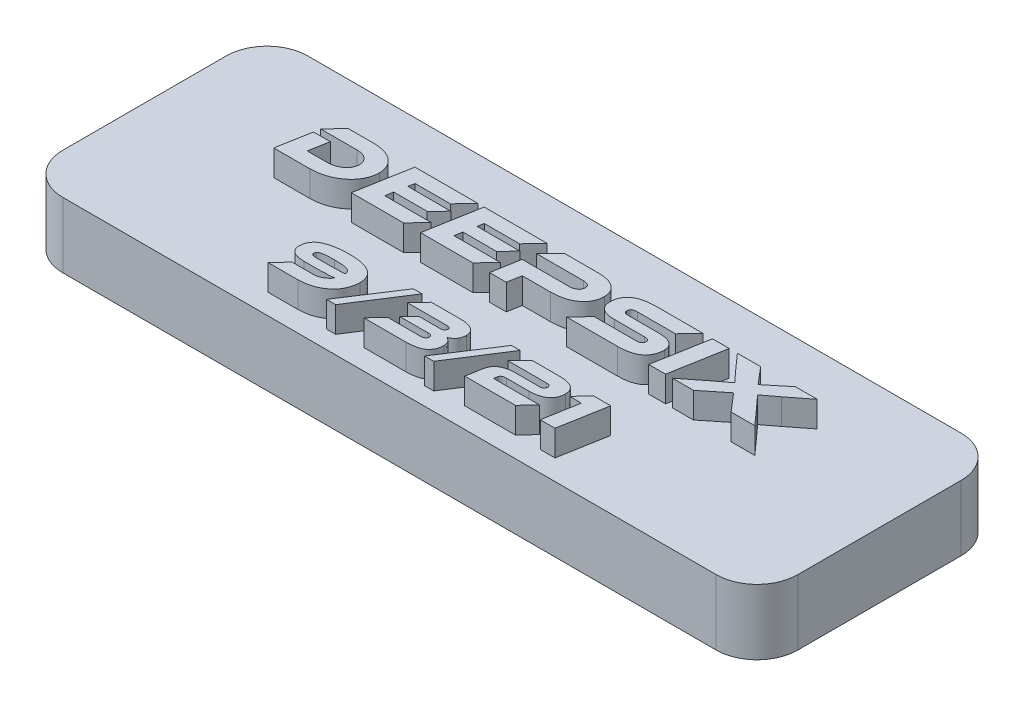
from build123d import *

# Parameters (mm, degrees)
SKETCH1_W           = 57.15
SKETCH1_H           = 19.05
BOSS_EXTRUDE1_DEPTH = 5.08
FILLET1_R           = 3.175
BOSS_EXTRUDE2_DEPTH = 2
SKETCH4_R           = 0.9
CUT_EXTRUDE1_DEPTH  = 4


with BuildPart() as part:
    # Sketch1 → Boss-Extrude1 (new body)
    with BuildSketch(Plane(origin=(0, 0, 0), x_dir=(1, 0, 0), z_dir=(0, 1, 0))):
        Rectangle(SKETCH1_W, SKETCH1_H)
    extrude(amount=BOSS_EXTRUDE1_DEPTH)

    # Fillet1
    fillet1_edges = [part.edges().sort_by_distance(p)[0] for p in [
        (-28.575, 2.54, -9.525),
        (-28.575, 2.54, 9.525),
        (28.575, 2.54, 9.525),
        (28.575, 2.54, -9.525),
    ]]
    fillet(fillet1_edges, radius=FILLET1_R)

    # Sketch3 → Boss-Extrude2 (add)
    with BuildSketch(Plane(origin=(0, 5.08, 0), x_dir=(1, 0, 0), z_dir=(0, 1, 0))):
        with BuildLine():
            Line((17.827066128, 4.208766837), (16.234744528, 2.901365975))
            Line((16.234744528, 2.901365975), (15.122646902, 4.208766837))
            Line((15.122646902, 4.208766837), (13.315488261, 4.208766837))
            Line((13.315488261, 4.208766837), (14.389673468, 3.001937264))
            add(Edge.make_bspline(
                [(14.389673468, 3.001937264), (14.421905514, 2.96565322), (14.483650914, 2.896145602), (14.574020121, 2.796969781), (14.656654904, 2.706215813), (14.731853226, 2.623295629), (14.800064219, 2.549789979), (14.861051093, 2.484598936), (14.913406566, 2.426996634), (14.972853904, 2.36453497), (15.036273052, 2.296940303), (15.105742475, 2.228942305), (15.164154185, 2.173290536), (15.200752002, 2.142040461), (15.217017295, 2.128151884)],
                knots=[0, 0, 0, 0, 0.000145597, 0.000278913, 0.000402513, 0.000513815, 0.000614729, 0.000703345, 0.000781627, 0.000848235, 0.000962032, 0.001059641, 0.001139837, 0.001203991, 0.001203991, 0.001203991, 0.001203991], degree=3))
            add(Edge.make_bspline(
                [(15.217017295, 2.128151884), (15.195035181, 2.113282778), (15.145882675, 2.08003512), (15.064926912, 2.02300337), (14.969735656, 1.952538971), (14.879324565, 1.885783864), (14.796949759, 1.822945094), (14.722685165, 1.767565893), (14.639482632, 1.703189998), (14.546501897, 1.630937748), (14.442983579, 1.551777369), (14.330544192, 1.463622082), (14.208356535, 1.36793568), (14.123681262, 1.30146059), (14.079808986, 1.267018261)],
                knots=[0, 0, 0, 0, 7.9615e-05, 0.000178022, 0.000297052, 0.000434907, 0.000515171, 0.000607866, 0.000712819, 0.000830759, 0.000961128, 0.001103763, 0.001259387, 0.001426717, 0.001426717, 0.001426717, 0.001426717], degree=3))
            Line((14.079808986, 1.267018261), (12.481415042, 0.003655726))
            Line((12.481415042, 0.003655726), (14.105330325, 0.003655726))
            Line((14.105330325, 0.003655726), (15.836664128, 1.392796648))
            Line((15.836664128, 1.392796648), (17.030905328, 0.003655726))
            Line((17.030905328, 0.003655726), (18.875976388, 0.003655726))
            Line((18.875976388, 0.003655726), (17.744922553, 1.267082537))
            add(Edge.make_bspline(
                [(17.744922553, 1.267082537), (17.696325554, 1.320639375), (17.602494366, 1.424047029), (17.467132294, 1.575101317), (17.338987839, 1.71398902), (17.222718612, 1.842642286), (17.119310283, 1.955855654), (17.029791837, 2.049203927), (16.956440111, 2.12197018), (16.911103789, 2.16153788), (16.891748502, 2.178430386)],
                knots=[0, 0, 0, 0, 0.000216956, 0.0004189, 0.000608483, 0.00078386, 0.000939132, 0.001068438, 0.001171871, 0.001248926, 0.001248926, 0.001248926, 0.001248926], degree=3))
            add(Edge.make_bspline(
                [(16.891748502, 2.178430386), (16.913422587, 2.193611207), (16.961906348, 2.227569887), (17.041709822, 2.285528044), (17.13592292, 2.355646824), (17.224966393, 2.421589531), (17.304693112, 2.483177947), (17.375746258, 2.536333869), (17.455085768, 2.596129235), (17.541485147, 2.664537016), (17.637795313, 2.737157725), (17.742177264, 2.816774485), (17.854334354, 2.903684473), (17.932047682, 2.96370059), (17.972279227, 2.994770435)],
                knots=[0, 0, 0, 0, 7.9384e-05, 0.000177578, 0.000295872, 0.000431716, 0.000509971, 0.000598095, 0.000697922, 0.000808005, 0.000928677, 0.001059771, 0.001201845, 0.001354342, 0.001354342, 0.001354342, 0.001354342], degree=3))
            Line((17.972279227, 2.994770435), (19.520487512, 4.208766837))
            Line((19.520487512, 4.208766837), (17.827066128, 4.208766837))
        make_face()
        Polygon((12.679904428, 4.208766837), (11.378244708, 4.208766837), (10.626315064, 0.003655726), (11.934293521, 0.003655726), align=None)
        with BuildLine():
            add(Edge.make_bspline(
                [(6.567629378, 2.512095919), (6.535775236, 2.511504671), (6.476212249, 2.510399118), (6.393389852, 2.522034835), (6.322632194, 2.539116782), (6.264835978, 2.566090201), (6.217459149, 2.599627964), (6.185992235, 2.644809044), (6.165140058, 2.696844794), (6.163885215, 2.734627087), (6.163230242, 2.754347778)],
                knots=[0, 0, 0, 0, 9.5419e-05, 0.000178421, 0.000250262, 0.000312834, 0.000368963, 0.000421992, 0.000475811, 0.000534573, 0.000534573, 0.000534573, 0.000534573], degree=3))
            add(Edge.make_bspline(
                [(6.163230242, 2.754347778), (6.16393416, 2.784095735), (6.165258572, 2.840066044), (6.188843823, 2.91717495), (6.226881216, 2.981488099), (6.283146184, 3.030808944), (6.35558579, 3.066687209), (6.4447633, 3.090054592), (6.550668454, 3.104410249), (6.626957211, 3.105638841), (6.667843575, 3.106297295)],
                knots=[0, 0, 0, 0, 8.8904e-05, 0.000167271, 0.000239077, 0.000310287, 0.000388377, 0.00047954, 0.000585681, 0.000708263, 0.000708263, 0.000708263, 0.000708263], degree=3))
            Line((6.667843575, 3.106297295), (9.600622902, 3.106887389))
            Line((9.600622902, 3.106887389), (10.636895689, 4.206347541))
            Line((10.636895689, 4.206347541), (6.965709778, 4.206347541))
            add(Edge.make_bspline(
                [(6.965709778, 4.206347541), (6.876741316, 4.203761609), (6.705199711, 4.19877563), (6.457529784, 4.177457512), (6.229750002, 4.141917495), (6.020578158, 4.09469606), (5.830218415, 4.035202214), (5.658791063, 3.962028529), (5.506468698, 3.876200662), (5.373887899, 3.776648192), (5.259482496, 3.666680115), (5.158520174, 3.550726447), (5.075014976, 3.425381253), (5.007102523, 3.292730634), (4.953286084, 3.153218365), (4.917105846, 3.005467482), (4.895463072, 2.850382913), (4.894142322, 2.744364115), (4.893469517, 2.690356957)],
                knots=[0, 0, 0, 0, 0.000266987, 0.000514782, 0.000745181, 0.000958069, 0.001157556, 0.001342649, 0.001516245, 0.001680793, 0.001838563, 0.001991558, 0.002141147, 0.00228915, 0.002437874, 0.00258864, 0.002744556, 0.002906454, 0.002906454, 0.002906454, 0.002906454], degree=3))
            add(Edge.make_bspline(
                [(4.893469517, 2.690356957), (4.894147376, 2.65342143), (4.895475926, 2.581030664), (4.911756384, 2.475706559), (4.936661127, 2.375589904), (4.974981165, 2.282563101), (5.021516713, 2.194076325), (5.08062567, 2.112868507), (5.149954093, 2.037166957), (5.229709741, 1.967522981), (5.321066112, 1.904593689), (5.424893806, 1.851271808), (5.539975017, 1.805334795), (5.667136696, 1.768282015), (5.805812009, 1.738303218), (5.95670207, 1.716643202), (6.119102931, 1.70292758), (6.231458964, 1.700608811), (6.289383575, 1.699413382)],
                knots=[0, 0, 0, 0, 0.000110707, 0.000216977, 0.00031897, 0.000419465, 0.000518033, 0.000618244, 0.00071983, 0.000825434, 0.000935228, 0.00105176, 0.001174832, 0.001306435, 0.001448624, 0.001600142, 0.001763438, 0.001937214, 0.001937214, 0.001937214, 0.001937214], degree=3))
            Line((6.289383575, 1.699413382), (8.595943797, 1.700326644))
            add(Edge.make_bspline(
                [(8.595943797, 1.700326644), (8.627002725, 1.699313028), (8.685116054, 1.697416487), (8.766553972, 1.687207317), (8.835667195, 1.668380389), (8.893309552, 1.642063474), (8.938553635, 1.606942061), (8.971304408, 1.563227804), (8.989955489, 1.510969449), (8.992256461, 1.473764602), (8.99345285, 1.454419952)],
                knots=[0, 0, 0, 0, 9.3208e-05, 0.000174398, 0.000245596, 0.000307341, 0.000363306, 0.000415597, 0.000469096, 0.000527043, 0.000527043, 0.000527043, 0.000527043], degree=3))
            add(Edge.make_bspline(
                [(8.99345285, 1.454419952), (8.992883896, 1.426558059), (8.991807608, 1.373851879), (8.970592701, 1.299313488), (8.930618572, 1.236775206), (8.873457266, 1.18629644), (8.799907561, 1.147494808), (8.709936912, 1.122375599), (8.604262417, 1.106843419), (8.528517367, 1.105781815), (8.487925362, 1.105212899)],
                knots=[0, 0, 0, 0, 8.3369e-05, 0.000157708, 0.000229223, 0.000303015, 0.000383999, 0.00047655, 0.000581916, 0.000703584, 0.000703584, 0.000703584, 0.000703584], degree=3))
            Line((8.487925362, 1.105212899), (5.281404943, 1.105536066))
            Line((5.281404943, 1.105536066), (4.249871655, 0.006075914))
            Line((4.249871655, 0.006075914), (8.19154466, 0.006075914))
            add(Edge.make_bspline(
                [(8.19154466, 0.006075914), (8.281244635, 0.008195652), (8.454473735, 0.012289302), (8.704369319, 0.034973018), (8.934899652, 0.071529273), (9.14625808, 0.119633447), (9.337781918, 0.182966981), (9.509690024, 0.258409984), (9.662591144, 0.347126316), (9.794603754, 0.450678649), (9.910000902, 0.563538193), (10.00775714, 0.686232854), (10.092324943, 0.815323858), (10.158838841, 0.953986469), (10.211730673, 1.099572383), (10.246666736, 1.254064377), (10.268813824, 1.415977891), (10.269343186, 1.52686752), (10.269612657, 1.583315749)],
                knots=[0, 0, 0, 0, 0.000269123, 0.000519731, 0.000752079, 0.000968942, 0.001169275, 0.001356304, 0.001531274, 0.001698041, 0.001858355, 0.0020144, 0.002167809, 0.002320308, 0.002474717, 0.002631488, 0.002794654, 0.002963834, 0.002963834, 0.002963834, 0.002963834], degree=3))
            add(Edge.make_bspline(
                [(10.269612657, 1.583315749), (10.267911832, 1.620553939), (10.264589517, 1.693293312), (10.24739464, 1.798622733), (10.218801084, 1.896846315), (10.179479639, 1.987941703), (10.128797123, 2.071957931), (10.066901021, 2.148122699), (9.994968474, 2.217510935), (9.911577648, 2.278743157), (9.818394786, 2.333809533), (9.713761444, 2.380099861), (9.599225452, 2.420439988), (9.473502129, 2.453105293), (9.336863127, 2.478118666), (9.18985923, 2.497622997), (9.031994275, 2.508032791), (8.923380917, 2.510110073), (8.867299517, 2.511182657)],
                knots=[0, 0, 0, 0, 0.000111766, 0.000218319, 0.000319279, 0.000417948, 0.00051515, 0.000612661, 0.00071158, 0.000814148, 0.000922328, 0.001035661, 0.001156803, 0.001286294, 0.001424887, 0.001573313, 0.001730929, 0.001899196, 0.001899196, 0.001899196, 0.001899196], degree=3))
            Line((8.867299517, 2.511182657), (6.567629378, 2.512095919))
        make_face()
        with BuildLine():
            add(Edge.make_bspline(
                [(4.334921063, 2.8527417), (4.333289643, 2.90231375), (4.330083108, 2.999746992), (4.306334363, 3.14197663), (4.270275615, 3.277108946), (4.218959506, 3.404564931), (4.151208352, 3.52306029), (4.07019455, 3.634253816), (3.975544816, 3.738655138), (3.865265959, 3.833025271), (3.742473371, 3.919798167), (3.605379714, 3.99434896), (3.455616067, 4.058920389), (3.292017684, 4.110009865), (3.116249204, 4.152486481), (2.927321206, 4.182135489), (2.725432173, 4.200187529), (2.586485545, 4.204039197), (2.514839275, 4.206025266)],
                knots=[0, 0, 0, 0, 0.000148656, 0.000292181, 0.000431448, 0.000567592, 0.000703091, 0.000839863, 0.000979636, 0.0011248, 0.001274431, 0.001429905, 0.001592071, 0.00176293, 0.001943415, 0.002134132, 0.002336075, 0.002551059, 0.002551059, 0.002551059, 0.002551059], degree=3))
            Line((2.514839275, 4.206025266), (-0.138744384, 4.206347541))
            Line((-0.138744384, 4.206347541), (-1.200292118, 3.106887389))
            Line((-1.200292118, 3.106887389), (2.439300111, 3.106887389))
            add(Edge.make_bspline(
                [(2.439300111, 3.106887389), (2.482542214, 3.105271439), (2.563862702, 3.102232508), (2.678131098, 3.082562512), (2.776238637, 3.049448147), (2.857548231, 3.002533217), (2.921309469, 2.944054673), (2.967950045, 2.875128596), (2.996394846, 2.795454755), (2.999547474, 2.738736187), (3.001169517, 2.709554203)],
                knots=[0, 0, 0, 0, 0.000129715, 0.000243941, 0.000346575, 0.000438764, 0.000523505, 0.000603877, 0.000686278, 0.000773603, 0.000773603, 0.000773603, 0.000773603], degree=3))
            add(Edge.make_bspline(
                [(3.001169517, 2.709554203), (3.0003594, 2.68940885), (2.99877984, 2.650129607), (2.98956586, 2.592714955), (2.97403491, 2.538325425), (2.951740618, 2.486997986), (2.924444503, 2.438376615), (2.891005306, 2.39293274), (2.85131362, 2.350727054), (2.78983583, 2.297975724), (2.698810384, 2.241909704), (2.571510264, 2.194774305), (2.426050313, 2.164290223), (2.322422657, 2.160374672), (2.268017536, 2.158318986)],
                knots=[0, 0, 0, 0, 6.0445e-05, 0.000117855, 0.000173984, 0.00022968, 0.000285354, 0.000340937, 0.0003985, 0.000458785, 0.000583594, 0.000716696, 0.00086425, 0.001027338, 0.001027338, 0.001027338, 0.001027338], degree=3))
            Line((2.268017536, 2.158318986), (-1.370898003, 2.158641261))
            Line((-1.370898003, 2.158641261), (-1.750022194, 0.003655726))
            Line((-1.750022194, 0.003655726), (-0.448362473, 0.003655726))
            Line((-0.448362473, 0.003655726), (-0.258800378, 1.059182001))
            Line((-0.258800378, 1.059182001), (1.9527574, 1.059182001))
            add(Edge.make_bspline(
                [(1.9527574, 1.059182001), (2.042992396, 1.061335988), (2.218714228, 1.065530619), (2.474081198, 1.093356204), (2.715190122, 1.132182566), (2.940529028, 1.189220643), (3.151872042, 1.259358952), (3.347791102, 1.345243266), (3.528983327, 1.445895761), (3.693839827, 1.561391424), (3.841774325, 1.688577723), (3.970621648, 1.826902301), (4.081780069, 1.973467635), (4.171571363, 2.131094192), (4.242786728, 2.29789434), (4.293631121, 2.47443279), (4.326549341, 2.660218917), (4.332097477, 2.787424299), (4.334921063, 2.8527417)],
                knots=[0, 0, 0, 0, 0.000270666, 0.000527089, 0.000769951, 0.001002752, 0.001223611, 0.001437281, 0.001643542, 0.001844398, 0.002040129, 0.002227698, 0.002410529, 0.002590701, 0.002770513, 0.002953344, 0.003140755, 0.003334978, 0.003334978, 0.003334978, 0.003334978], degree=3))
        make_face()
        Polygon((-5.616067654, 1.105536066), (-5.51496787, 1.700326644), (-2.911648429, 1.700326644), (-2.001750372, 2.629107706), (-5.344361984, 2.629107706), (-5.255899673, 3.106887389), (-2.519886766, 3.106887389), (-1.477295242, 4.206347541), (-6.367997299, 4.206347541), (-7.119926943, 0.006075914), (-3.050660632, 0.006075914), (-2.014387845, 1.105536066), align=None)
        Polygon((-10.998609876, 1.105536066), (-10.897510092, 1.700326644), (-8.294190651, 1.700326644), (-7.384292594, 2.629107706), (-10.726904207, 2.629107706), (-10.638441896, 3.106887389), (-7.902428988, 3.106887389), (-6.859837464, 4.206347541), (-11.750539521, 4.206347541), (-12.502469165, 0.006075914), (-8.433202854, 0.006075914), (-7.396930067, 1.105536066), align=None)
        with BuildLine():
            add(Edge.make_bspline(
                [(-12.740613578, 2.425376215), (-12.743489292, 2.490366785), (-12.749139702, 2.618064917), (-12.780947082, 2.803986167), (-12.82957769, 2.980115123), (-12.895111257, 3.146960648), (-12.981308413, 3.303299496), (-13.084740044, 3.450058323), (-13.206982425, 3.586303096), (-13.345541518, 3.712179584), (-13.500548921, 3.825344313), (-13.668963286, 3.925395962), (-13.851178821, 4.009390478), (-14.046042357, 4.079106767), (-14.2541122, 4.133528035), (-14.475311252, 4.173811565), (-14.709750897, 4.198189582), (-14.870496912, 4.203371321), (-14.952826618, 4.206025266)],
                knots=[0, 0, 0, 0, 0.000195009, 0.000383167, 0.000564368, 0.00074244, 0.000919581, 0.001098646, 0.001279935, 0.00146761, 0.001659228, 0.001854731, 0.002054318, 0.002260196, 0.002474835, 0.002698788, 0.00293411, 0.003181175, 0.003181175, 0.003181175, 0.003181175], degree=3))
            Line((-14.952826618, 4.206025266), (-16.948892092, 4.206347541))
            Line((-16.948892092, 4.206347541), (-17.978846142, 3.106887389))
            Line((-17.978846142, 3.106887389), (-15.148052187, 3.106887389))
            add(Edge.make_bspline(
                [(-15.148052187, 3.106887389), (-15.108540287, 3.105364711), (-15.031324045, 3.102389015), (-14.918702398, 3.089591847), (-14.812009382, 3.069582481), (-14.711161026, 3.04202105), (-14.615798939, 3.008030543), (-14.527668541, 2.964107485), (-14.444805262, 2.914773344), (-14.368041927, 2.858665576), (-14.300127246, 2.795181395), (-14.238448718, 2.72884043), (-14.188618491, 2.655711823), (-14.145804657, 2.579167986), (-14.111573945, 2.49778013), (-14.088578205, 2.411231968), (-14.07204699, 2.320728819), (-14.069320272, 2.258648084), (-14.067924976, 2.22688058)],
                knots=[0, 0, 0, 0, 0.000118592, 0.000231759, 0.000339692, 0.000443921, 0.000545141, 0.000642853, 0.0007388, 0.00083424, 0.000927403, 0.001017368, 0.001105364, 0.001192113, 0.001280223, 0.00136938, 0.001460305, 0.001555592, 0.001555592, 0.001555592, 0.001555592], degree=3))
            add(Edge.make_bspline(
                [(-14.067924976, 2.22688058), (-14.07036942, 2.185642711), (-14.075164159, 2.104755276), (-14.09770486, 1.98706422), (-14.131211115, 1.87545354), (-14.178338585, 1.770616802), (-14.237584214, 1.672112744), (-14.307872606, 1.579018173), (-14.392451795, 1.493971369), (-14.486889881, 1.414841832), (-14.591107162, 1.343689091), (-14.70276201, 1.281927096), (-14.820395465, 1.227960987), (-14.94566522, 1.185692043), (-15.076826559, 1.150471437), (-15.215174653, 1.126576329), (-15.359501459, 1.109169924), (-15.458299838, 1.106548421), (-15.508632609, 1.105212899)],
                knots=[0, 0, 0, 0, 0.00012382, 0.000242871, 0.000358539, 0.000472706, 0.000586683, 0.000702784, 0.000821729, 0.000945681, 0.001071953, 0.001199634, 0.001328098, 0.001459638, 0.001595783, 0.001735109, 0.00188048, 0.002031451, 0.002031451, 0.002031451, 0.002031451], degree=3))
            Line((-15.508632609, 1.105212899), (-17.02471693, 1.105536066))
            Line((-17.02471693, 1.105536066), (-16.75301126, 2.623662059))
            Line((-16.75301126, 2.623662059), (-18.060989717, 2.623662059))
            Line((-18.060989717, 2.623662059), (-18.528576218, 0.006075914))
            Line((-18.528576218, 0.006075914), (-15.697782263, 0.006075914))
            add(Edge.make_bspline(
                [(-15.697782263, 0.006075914), (-15.595914887, 0.00973645), (-15.39575895, 0.016928919), (-15.10238127, 0.055361686), (-14.821787737, 0.113609118), (-14.553911214, 0.192345638), (-14.298469148, 0.290947451), (-14.056292615, 0.411678855), (-13.825841974, 0.551302588), (-13.646467493, 0.685730436), (-13.511181152, 0.801137626), (-13.415990539, 0.891127884), (-13.32649999, 0.98286194), (-13.243606673, 1.077854124), (-13.166845226, 1.175378809), (-13.096669559, 1.275986307), (-13.031941618, 1.378755373), (-12.974811286, 1.484675691), (-12.923236233, 1.592866707), (-12.878347962, 1.703675086), (-12.840141023, 1.817381495), (-12.807043609, 1.933500983), (-12.78018743, 2.052449268), (-12.761710277, 2.174419147), (-12.747278018, 2.298802205), (-12.743428298, 2.38285802), (-12.740613578, 2.425376215)],
                knots=[0, 0, 0, 0, 0.000305659, 0.00060058, 0.000886364, 0.001164634, 0.001437273, 0.001706688, 0.001975409, 0.002244537, 0.002378097, 0.002508729, 0.002637378, 0.002762417, 0.002886772, 0.003009517, 0.003130255, 0.003250927, 0.003370328, 0.003489667, 0.003609348, 0.003730019, 0.003851781, 0.003974869, 0.004099948, 0.004227226, 0.004227226, 0.004227226, 0.004227226], degree=3))
        make_face()
        Polygon((9.710846154, -5.218973535), (10.612055948, -5.218973535), (10.131042132, -7.93430124), (11.275523281, -7.93430124), (11.93346172, -4.256945902), (10.578882582, -4.256945902), align=None)
        with BuildLine():
            Line((4.894237041, -5.218973535), (7.885368935, -5.218973535))
            add(Edge.make_bspline(
                [(7.885368935, -5.218973535), (7.913069849, -5.218922741), (7.964916224, -5.218827674), (8.037645227, -5.225918073), (8.099169268, -5.242216387), (8.150999805, -5.26353583), (8.191093194, -5.294908436), (8.219407194, -5.334273792), (8.236959171, -5.381008794), (8.238183871, -5.4147712), (8.238818237, -5.432259348)],
                knots=[0, 0, 0, 0, 8.3099e-05, 0.000155531, 0.000218392, 0.000273538, 0.000322508, 0.000368908, 0.000417497, 0.000469711, 0.000469711, 0.000469711, 0.000469711], degree=3))
            add(Edge.make_bspline(
                [(8.238818237, -5.432259348), (8.238178443, -5.458018948), (8.236968839, -5.506720508), (8.216406453, -5.573936821), (8.183120077, -5.630194031), (8.133906454, -5.673414306), (8.070375355, -5.704561408), (7.992641188, -5.726311626), (7.899516029, -5.738498194), (7.832514384, -5.73961472), (7.796481685, -5.740215175)],
                knots=[0, 0, 0, 0, 7.6993e-05, 0.000145564, 0.000208395, 0.000270703, 0.000339032, 0.00041902, 0.000511893, 0.000619952, 0.000619952, 0.000619952, 0.000619952], degree=3))
            Line((7.796481685, -5.740215175), (6.038718191, -5.739416071))
            add(Edge.make_bspline(
                [(6.038718191, -5.739416071), (5.983116035, -5.740560639), (5.874862873, -5.742789025), (5.716867546, -5.753609346), (5.568148187, -5.772857955), (5.428525319, -5.798779792), (5.298262121, -5.833149331), (5.177183268, -5.875619954), (5.064915888, -5.92500466), (4.961714021, -5.98174212), (4.868244824, -6.047028209), (4.783719331, -6.120143527), (4.708318722, -6.201107035), (4.6423177, -6.289606037), (4.585936126, -6.385733808), (4.538840371, -6.489539314), (4.499893008, -6.600822081), (4.482571332, -6.678800473), (4.473758291, -6.718474855)],
                knots=[0, 0, 0, 0, 0.000166829, 0.000324804, 0.000474816, 0.000616477, 0.000750546, 0.000878553, 0.001001026, 0.001118108, 0.001231277, 0.001342418, 0.001452782, 0.001562526, 0.00167296, 0.001786425, 0.001904052, 0.002025887, 0.002025887, 0.002025887, 0.002025887], degree=3))
            Line((4.473758291, -6.718474855), (4.25841418, -7.932183575))
            Line((4.25841418, -7.932183575), (8.194987024, -7.932183575))
            Line((8.194987024, -7.932183575), (9.101725713, -6.970155942))
            Line((9.101725713, -6.970155942), (5.530059902, -6.970155942))
            Line((5.530059902, -6.970155942), (5.579819952, -6.707239748))
            add(Edge.make_bspline(
                [(5.579819952, -6.707239748), (5.583597476, -6.686112106), (5.590920233, -6.645156023), (5.619631586, -6.590591717), (5.657992279, -6.543848716), (5.70933161, -6.508043577), (5.770407077, -6.47963759), (5.842724697, -6.461031101), (5.925788118, -6.450993538), (5.984711628, -6.450679637), (6.015937083, -6.450513291)],
                knots=[0, 0, 0, 0, 6.4036e-05, 0.000124134, 0.000182613, 0.000243892, 0.000310094, 0.000383827, 0.000466868, 0.000560486, 0.000560486, 0.000560486, 0.000560486], degree=3))
            Line((6.015937083, -6.450513291), (7.774791046, -6.449714187))
            add(Edge.make_bspline(
                [(7.774791046, -6.449714187), (7.840472071, -6.448593152), (7.967806512, -6.446419826), (8.151704361, -6.426694059), (8.323120971, -6.400940141), (8.480967857, -6.361961645), (8.626721851, -6.315052912), (8.758063106, -6.255202462), (8.877536221, -6.187512089), (8.982248661, -6.107690588), (9.074831853, -6.020066732), (9.155288214, -5.925525662), (9.223067099, -5.823724541), (9.278819901, -5.715194429), (9.32095587, -5.599220599), (9.351651306, -5.476792913), (9.369306651, -5.347458364), (9.371259605, -5.259004345), (9.372255658, -5.21389067)],
                knots=[0, 0, 0, 0, 0.00019697, 0.000381861, 0.000554393, 0.000716581, 0.000869107, 0.001013024, 0.00114885, 0.001280192, 0.001406932, 0.001530654, 0.001651783, 0.001773055, 0.001895792, 0.002021116, 0.002151095, 0.002286391, 0.002286391, 0.002286391, 0.002286391], degree=3))
            add(Edge.make_bspline(
                [(9.372255658, -5.21389067), (9.371803203, -5.1780961), (9.370917459, -5.108023129), (9.354707611, -5.005989197), (9.330715539, -4.909275966), (9.294180836, -4.818686266), (9.246546483, -4.734234215), (9.188467441, -4.655338408), (9.120099814, -4.582231577), (9.040805374, -4.515185386), (8.949982457, -4.455053695), (8.846403837, -4.402688892), (8.730170716, -4.359688685), (8.601983237, -4.322394884), (8.461180228, -4.294289614), (8.307833182, -4.27367202), (8.141966652, -4.26108405), (8.027137036, -4.258543735), (7.967657132, -4.257227893)],
                knots=[0, 0, 0, 0, 0.000107259, 0.000209975, 0.000309113, 0.00040566, 0.000501999, 0.00059927, 0.000698874, 0.0008016, 0.000910084, 0.001024914, 0.001148961, 0.001281358, 0.001425053, 0.00157924, 0.00174531, 0.001923772, 0.001923772, 0.001923772, 0.001923772], degree=3))
            Line((7.967657132, -4.257227893), (5.80097573, -4.256945902))
            Line((5.80097573, -4.256945902), (4.894237041, -5.218973535))
        make_face()
        Polygon((4.0084266, -4.05005839), (1.343499478, -8.139071868), (2.056726861, -8.139071868), (4.682951722, -4.05005839), align=None)
        with BuildLine():
            Line((-3.584918597, -7.932183575), (-0.32839977, -7.932183575))
            add(Edge.make_bspline(
                [(-0.32839977, -7.932183575), (-0.286383473, -7.93123587), (-0.204058777, -7.929378983), (-0.083062886, -7.923037277), (0.032654988, -7.913254577), (0.143430248, -7.901623973), (0.248731668, -7.886187648), (0.348917171, -7.869042189), (0.44351634, -7.847894486), (0.532746284, -7.825100472), (0.616861791, -7.799290342), (0.695389706, -7.77082736), (0.768980747, -7.739583859), (0.836820825, -7.704897995), (0.900347943, -7.668886302), (0.957258697, -7.627851966), (1.010281081, -7.586408565), (1.071505268, -7.526093275), (1.139716862, -7.447939794), (1.210293914, -7.349103621), (1.270061869, -7.247349748), (1.317566646, -7.141977162), (1.353040099, -7.033365496), (1.376318121, -6.921258258), (1.387751117, -6.805632209), (1.386190462, -6.727558847), (1.38540128, -6.688079215)],
                knots=[0, 0, 0, 0, 0.000126077, 0.000247029, 0.000363409, 0.000474443, 0.000581116, 0.000682639, 0.000779289, 0.000871831, 0.000958868, 0.001043129, 0.001122322, 0.001198517, 0.00127164, 0.001341101, 0.001408809, 0.001473297, 0.001598583, 0.001719557, 0.001837129, 0.001952051, 0.002065626, 0.002179204, 0.002294931, 0.002413314, 0.002413314, 0.002413314, 0.002413314], degree=3))
            add(Edge.make_bspline(
                [(1.38540128, -6.688079215), (1.383378638, -6.645034748), (1.379486094, -6.562196351), (1.354941173, -6.444259027), (1.313727655, -6.339492999), (1.258278681, -6.247902175), (1.189498154, -6.171048672), (1.111679574, -6.10652163), (1.02360285, -6.055707807), (0.958996435, -6.034777591), (0.926267138, -6.024174444)],
                knots=[0, 0, 0, 0, 0.000129139, 0.000248525, 0.000359482, 0.000465388, 0.000567951, 0.000667397, 0.000767703, 0.000870689, 0.000870689, 0.000870689, 0.000870689], degree=3))
            add(Edge.make_bspline(
                [(0.926267138, -6.024174444), (0.967597793, -6.009960653), (1.050881944, -5.981318874), (1.167342108, -5.914739414), (1.277069116, -5.831227741), (1.361893804, -5.748532962), (1.423284875, -5.672798575), (1.46461194, -5.610121102), (1.498699672, -5.541280496), (1.528345607, -5.468161351), (1.551857412, -5.389726388), (1.567910247, -5.306040388), (1.580621101, -5.217443624), (1.583235735, -5.156345524), (1.584572711, -5.125103406)],
                knots=[0, 0, 0, 0, 0.000130881, 0.000263734, 0.000400196, 0.000543864, 0.000617818, 0.000692362, 0.000768557, 0.000847875, 0.000928857, 0.001013724, 0.001103318, 0.001197072, 0.001197072, 0.001197072, 0.001197072], degree=3))
            add(Edge.make_bspline(
                [(1.584572711, -5.125103406), (1.583232965, -5.090373417), (1.580629974, -5.022896543), (1.563583248, -4.924759117), (1.53551598, -4.833556952), (1.497778687, -4.74840209), (1.449247298, -4.670190772), (1.390585569, -4.598383368), (1.320535253, -4.534139714), (1.241382205, -4.475547046), (1.152050841, -4.424861588), (1.054892809, -4.380021469), (0.949596513, -4.341403135), (0.83580636, -4.310565354), (0.713906689, -4.286619559), (0.583737532, -4.270262105), (0.445441228, -4.259706834), (0.350369752, -4.258068877), (0.301556745, -4.257227893)],
                knots=[0, 0, 0, 0, 0.000104182, 0.000202415, 0.000297803, 0.000389821, 0.000481053, 0.000573127, 0.000667078, 0.000765468, 0.000867956, 0.000974605, 0.001086203, 0.001203992, 0.00132792, 0.001458586, 0.001597356, 0.00174379, 0.00174379, 0.00174379, 0.00174379], degree=3))
            Line((0.301556745, -4.257227893), (-2.014712575, -4.256945902))
            Line((-2.014712575, -4.256945902), (-2.921451264, -5.218973535))
            Line((-2.921451264, -5.218973535), (0.174729625, -5.218973535))
            add(Edge.make_bspline(
                [(0.174729625, -5.218973535), (0.192782503, -5.219195663), (0.227868319, -5.219627369), (0.278607316, -5.228283394), (0.326267388, -5.240429742), (0.369072365, -5.259411957), (0.40660968, -5.284007636), (0.434912262, -5.317589756), (0.451051155, -5.359825366), (0.45425199, -5.390000635), (0.455934601, -5.405863134)],
                knots=[0, 0, 0, 0, 5.4079e-05, 0.000105103, 0.000154, 0.000201268, 0.000244977, 0.000287582, 0.000330657, 0.000378396, 0.000378396, 0.000378396, 0.000378396], degree=3))
            add(Edge.make_bspline(
                [(0.455934601, -5.405863134), (0.454096284, -5.430312402), (0.450621522, -5.476526055), (0.428791972, -5.540002066), (0.393505772, -5.592061965), (0.344494627, -5.629761186), (0.288180517, -5.655905201), (0.226965097, -5.675731181), (0.160648348, -5.686777079), (0.114689202, -5.68773353), (0.09118692, -5.688222633)],
                knots=[0, 0, 0, 0, 7.3319e-05, 0.000138587, 0.00019894, 0.000259277, 0.000321525, 0.000384513, 0.000451841, 0.000522304, 0.000522304, 0.000522304, 0.000522304], degree=3))
            Line((0.09118692, -5.688222633), (-1.550285442, -5.688222633))
            Line((-1.550285442, -5.688222633), (-2.285628403, -6.449714187))
            Line((-2.285628403, -6.449714187), (-0.068541731, -6.449714187))
            add(Edge.make_bspline(
                [(-0.068541731, -6.449714187), (-0.042983599, -6.450477347), (0.004719616, -6.451901753), (0.071259449, -6.462295485), (0.12767871, -6.478314945), (0.174342181, -6.50173535), (0.210582503, -6.532597577), (0.236576106, -6.570559095), (0.250347166, -6.615980043), (0.25140557, -6.647995141), (0.251963859, -6.664882542)],
                knots=[0, 0, 0, 0, 7.6645e-05, 0.000143055, 0.000201512, 0.000251956, 0.000298459, 0.000342829, 0.000388113, 0.000438664, 0.000438664, 0.000438664, 0.000438664], degree=3))
            add(Edge.make_bspline(
                [(0.251963859, -6.664882542), (0.251487855, -6.688229704), (0.250578437, -6.732835091), (0.231350974, -6.795336816), (0.199782738, -6.849505947), (0.152563101, -6.892453142), (0.093910868, -6.927804649), (0.020929858, -6.950272738), (-0.063791542, -6.966892139), (-0.124947739, -6.969204801), (-0.157577397, -6.970438714)],
                knots=[0, 0, 0, 0, 6.9755e-05, 0.000133269, 0.000193903, 0.000255577, 0.000322658, 0.000397783, 0.000483281, 0.000581077, 0.000581077, 0.000581077, 0.000581077], degree=3))
            Line((-0.157577397, -6.970438714), (-2.689237697, -6.970155942))
            Line((-2.689237697, -6.970155942), (-3.584918597, -7.932183575))
        make_face()
        Polygon((-3.619279294, -4.05005839), (-6.284206416, -8.139071868), (-5.570979032, -8.139071868), (-2.944754172, -4.05005839), align=None)
        with BuildLine():
            Line((-10.1341784, -6.970155942), (-11.029434361, -7.932183575))
            Line((-11.029434361, -7.932183575), (-8.711256721, -7.932183575))
            add(Edge.make_bspline(
                [(-8.711256721, -7.932183575), (-8.621410464, -7.929777147), (-8.444840762, -7.92504793), (-8.185829898, -7.89377972), (-7.937790567, -7.845456505), (-7.701302252, -7.778119368), (-7.476029452, -7.693257531), (-7.262352982, -7.589683886), (-7.060269533, -7.467776465), (-6.902088472, -7.351552012), (-6.78285318, -7.251102183), (-6.699503392, -7.171271707), (-6.620978372, -7.089073015), (-6.547763185, -7.003301544), (-6.481023729, -6.913691428), (-6.418689744, -6.821436558), (-6.363128272, -6.725101624), (-6.311473615, -6.626227548), (-6.2668142, -6.523415525), (-6.22764326, -6.417304195), (-6.193003164, -6.308297587), (-6.165399273, -6.195383605), (-6.141648073, -6.079711014), (-6.125602368, -5.960192069), (-6.112964463, -5.837767761), (-6.109616535, -5.75491021), (-6.107923889, -5.713019076)],
                knots=[0, 0, 0, 0, 0.000269512, 0.000529657, 0.000781592, 0.001026938, 0.001266417, 0.001502887, 0.001738287, 0.001973466, 0.00209094, 0.002205793, 0.002319514, 0.002431869, 0.002543853, 0.002654555, 0.002765679, 0.002877297, 0.002989052, 0.003101677, 0.003216532, 0.003331962, 0.003450243, 0.003570604, 0.003693573, 0.003819318, 0.003819318, 0.003819318, 0.003819318], degree=3))
            add(Edge.make_bspline(
                [(-6.107923889, -5.713019076), (-6.110049009, -5.652117472), (-6.1141828, -5.533651456), (-6.142571426, -5.361744864), (-6.188860208, -5.20161806), (-6.253081491, -5.05300733), (-6.335699155, -4.916595218), (-6.435227494, -4.79126316), (-6.554928255, -4.67984859), (-6.690382543, -4.578328397), (-6.845085026, -4.490460709), (-7.016819167, -4.413762538), (-7.206498998, -4.349318484), (-7.413562974, -4.296844754), (-7.638423939, -4.256528236), (-7.880933649, -4.227593809), (-8.141195036, -4.208531898), (-8.32063751, -4.206884801), (-8.413193225, -4.206035236)],
                knots=[0, 0, 0, 0, 0.00018267, 0.00035533, 0.000521131, 0.000681619, 0.000839513, 0.000998287, 0.001160113, 0.00132873, 0.001505033, 0.001692644, 0.001892226, 0.002105242, 0.002332894, 0.00257706, 0.002837673, 0.00311529, 0.00311529, 0.00311529, 0.00311529], degree=3))
            add(Edge.make_bspline(
                [(-8.413193225, -4.206035236), (-8.496392079, -4.205592276), (-8.659930908, -4.204721577), (-8.90116953, -4.215578286), (-9.133990357, -4.234927868), (-9.358416509, -4.265660573), (-9.574563808, -4.305110003), (-9.78198535, -4.355643498), (-9.980905558, -4.415783415), (-10.140350074, -4.473503284), (-10.262210292, -4.525130752), (-10.346676637, -4.569635858), (-10.426684314, -4.616422557), (-10.499891343, -4.668834502), (-10.56877088, -4.723868288), (-10.630979169, -4.784450305), (-10.688946934, -4.847987079), (-10.740311989, -4.916899938), (-10.786693576, -4.989145242), (-10.826874435, -5.066161285), (-10.862116829, -5.146801308), (-10.891681935, -5.2318633), (-10.915685955, -5.32088445), (-10.933951484, -5.41389817), (-10.946975097, -5.510872203), (-10.950855436, -5.57700115), (-10.952828943, -5.610633762)],
                knots=[0, 0, 0, 0, 0.000249565, 0.000490555, 0.000724179, 0.0009502, 0.001169841, 0.001383052, 0.001590297, 0.00179299, 0.001891509, 0.001987031, 0.002079216, 0.002169319, 0.002256891, 0.002343445, 0.002429536, 0.002514644, 0.002600961, 0.002686833, 0.002774954, 0.002864759, 0.002956732, 0.003051325, 0.003148954, 0.003249996, 0.003249996, 0.003249996, 0.003249996], degree=3))
            add(Edge.make_bspline(
                [(-10.952828943, -5.610633762), (-10.951394089, -5.643753438), (-10.948588592, -5.708510641), (-10.932707199, -5.802650158), (-10.905719784, -5.890402518), (-10.870916567, -5.972873051), (-10.824799185, -6.048807605), (-10.768234836, -6.117637999), (-10.702623742, -6.18094304), (-10.627159241, -6.237416652), (-10.543193181, -6.287658407), (-10.451167228, -6.330947125), (-10.351560835, -6.367615523), (-10.24412204, -6.398128227), (-10.128746954, -6.420818141), (-10.005888135, -6.437537883), (-9.875561277, -6.448004733), (-9.786082694, -6.449663014), (-9.74020288, -6.450513291)],
                knots=[0, 0, 0, 0, 9.9392e-05, 0.000194336, 0.000285432, 0.000374287, 0.00046222, 0.000550917, 0.000640864, 0.000735091, 0.000833037, 0.000933937, 0.001039728, 0.001151139, 0.001268635, 0.001392165, 0.00152296, 0.001660599, 0.001660599, 0.001660599, 0.001660599], degree=3))
            add(Edge.make_bspline(
                [(-9.74020288, -6.450513291), (-9.686610375, -6.450588766), (-9.581824333, -6.450736339), (-9.428247631, -6.449683936), (-9.281335315, -6.448934551), (-9.141355104, -6.448155746), (-9.008041814, -6.447263447), (-8.881654136, -6.446777451), (-8.761943212, -6.444902162), (-8.648891307, -6.443402764), (-8.542776033, -6.441665317), (-8.443574534, -6.440519694), (-8.351081454, -6.437415789), (-8.265465437, -6.436504009), (-8.186556008, -6.433778787), (-8.114569717, -6.43134803), (-8.04921299, -6.429349577), (-7.9724726, -6.424605461), (-7.885214198, -6.420771207), (-7.787945774, -6.413793257), (-7.699346421, -6.408049685), (-7.619472503, -6.400065169), (-7.548086835, -6.394706302), (-7.485795565, -6.386176476), (-7.432134436, -6.378534723), (-7.399456472, -6.372485855), (-7.384540773, -6.369724879)],
                knots=[0, 0, 0, 0, 0.000160777, 0.000314357, 0.000460738, 0.00060152, 0.000734304, 0.000860688, 0.000980681, 0.001093477, 0.001199873, 0.001299072, 0.00139109, 0.001477493, 0.001555918, 0.001627948, 0.001693582, 0.001752061, 0.001858593, 0.001955591, 0.002044608, 0.00212492, 0.002196397, 0.002259299, 0.002313485, 0.002358987, 0.002358987, 0.002358987, 0.002358987], degree=3))
            add(Edge.make_bspline(
                [(-7.384540773, -6.369724879), (-7.414261829, -6.410755391), (-7.474107101, -6.493372984), (-7.581801202, -6.604032197), (-7.701725296, -6.70577684), (-7.812268259, -6.780745718), (-7.907224301, -6.833676621), (-7.982024054, -6.868964979), (-8.059264509, -6.899761591), (-8.140156427, -6.923136897), (-8.223232609, -6.943784293), (-8.309950021, -6.957621584), (-8.39936696, -6.967749518), (-8.460091072, -6.969535864), (-8.490782095, -6.970438714)],
                knots=[0, 0, 0, 0, 0.000151822, 0.000305704, 0.000461788, 0.000623076, 0.000705429, 0.000787724, 0.000871054, 0.000954565, 0.001040123, 0.001127702, 0.001217802, 0.001309875, 0.001309875, 0.001309875, 0.001309875], degree=3))
            Line((-8.490782095, -6.970438714), (-10.1341784, -6.970155942))
        make_face()
        with BuildLine():
            add(Edge.make_bspline(
                [(-9.524004204, -5.739416071), (-9.552389222, -5.739333167), (-9.605577937, -5.739177819), (-9.679328265, -5.728388524), (-9.742215669, -5.712937853), (-9.794138814, -5.691097621), (-9.835258049, -5.66209877), (-9.863472789, -5.625127048), (-9.881605078, -5.582069955), (-9.882775775, -5.550830586), (-9.883382343, -5.534644662)],
                knots=[0, 0, 0, 0, 8.5051e-05, 0.000159372, 0.000223007, 0.000278884, 0.00032752, 0.000371998, 0.000416856, 0.000465088, 0.000465088, 0.000465088, 0.000465088], degree=3))
            add(Edge.make_bspline(
                [(-9.883382343, -5.534644662), (-9.884584629, -5.520492659), (-9.886938555, -5.492784798), (-9.87899188, -5.451904192), (-9.863711991, -5.413284736), (-9.838797658, -5.377865243), (-9.806510655, -5.344746874), (-9.765245751, -5.315137149), (-9.716617334, -5.287204256), (-9.658133632, -5.262102266), (-9.587638688, -5.239181686), (-9.501499799, -5.220969825), (-9.399557666, -5.204302076), (-9.281286075, -5.19102051), (-9.14681825, -5.180808804), (-8.995827086, -5.174134861), (-8.828634472, -5.169033665), (-8.711821634, -5.168550026), (-8.650759149, -5.16829721)],
                knots=[0, 0, 0, 0, 4.2424e-05, 8.3061e-05, 0.000123611, 0.000166209, 0.000212026, 0.00026178, 0.000318034, 0.000380003, 0.000452348, 0.000540062, 0.000643816, 0.000762183, 0.000896965, 0.001048315, 0.00121556, 0.00139874, 0.00139874, 0.00139874, 0.00139874], degree=3))
            add(Edge.make_bspline(
                [(-8.650759149, -5.16829721), (-8.59823262, -5.167787601), (-8.496106704, -5.166796781), (-8.347561906, -5.169363834), (-8.20828181, -5.174373781), (-8.07845543, -5.184530804), (-7.95775916, -5.195834798), (-7.846376531, -5.211544935), (-7.744637012, -5.232098586), (-7.651424063, -5.253456427), (-7.567803304, -5.280784321), (-7.49431335, -5.316195779), (-7.431671038, -5.359607715), (-7.378102803, -5.409671023), (-7.336361787, -5.468468051), (-7.303507134, -5.534032814), (-7.283060297, -5.607713922), (-7.277178334, -5.659314386), (-7.274156606, -5.685822977)],
                knots=[0, 0, 0, 0, 0.000157579, 0.000306377, 0.00044567, 0.000575606, 0.000696984, 0.000809313, 0.000912848, 0.001008299, 0.001096072, 0.001176204, 0.001252088, 0.00132394, 0.001394981, 0.001467241, 0.001542944, 0.00162292, 0.00162292, 0.00162292, 0.00162292], degree=3))
            add(Edge.make_bspline(
                [(-7.274156606, -5.685822977), (-7.291747311, -5.688016622), (-7.329294776, -5.692698971), (-7.38905186, -5.698817251), (-7.455626655, -5.705774202), (-7.529053723, -5.709867374), (-7.609029479, -5.714809123), (-7.695666031, -5.719762177), (-7.788996792, -5.723691176), (-7.892196397, -5.726773296), (-8.011366255, -5.730355113), (-8.152963268, -5.73231403), (-8.319870653, -5.734779827), (-8.511840146, -5.737306699), (-8.729145621, -5.738848781), (-8.97177991, -5.739352636), (-9.239740538, -5.740463735), (-9.42664772, -5.740300435), (-9.524004204, -5.739416071)],
                knots=[0, 0, 0, 0, 5.3179e-05, 0.000113511, 0.000180209, 0.000253954, 0.000334087, 0.000420608, 0.00051428, 0.000614317, 0.000730344, 0.000871944, 0.001039137, 0.001231125, 0.0014479, 0.001691066, 0.001959029, 0.002251787, 0.002251787, 0.002251787, 0.002251787], degree=3))
        make_face(mode=Mode.SUBTRACT)
    extrude(amount=BOSS_EXTRUDE2_DEPTH)

    # Sketch4 → Cut-Extrude1 (cut)
    with BuildSketch(Plane.XZ):
        with Locations((-25.4, 0)):
            Circle(SKETCH4_R)
        with Locations((25.4, 0)):
            Circle(SKETCH4_R)
    extrude(amount=-CUT_EXTRUDE1_DEPTH, mode=Mode.SUBTRACT)


solid = part.part
